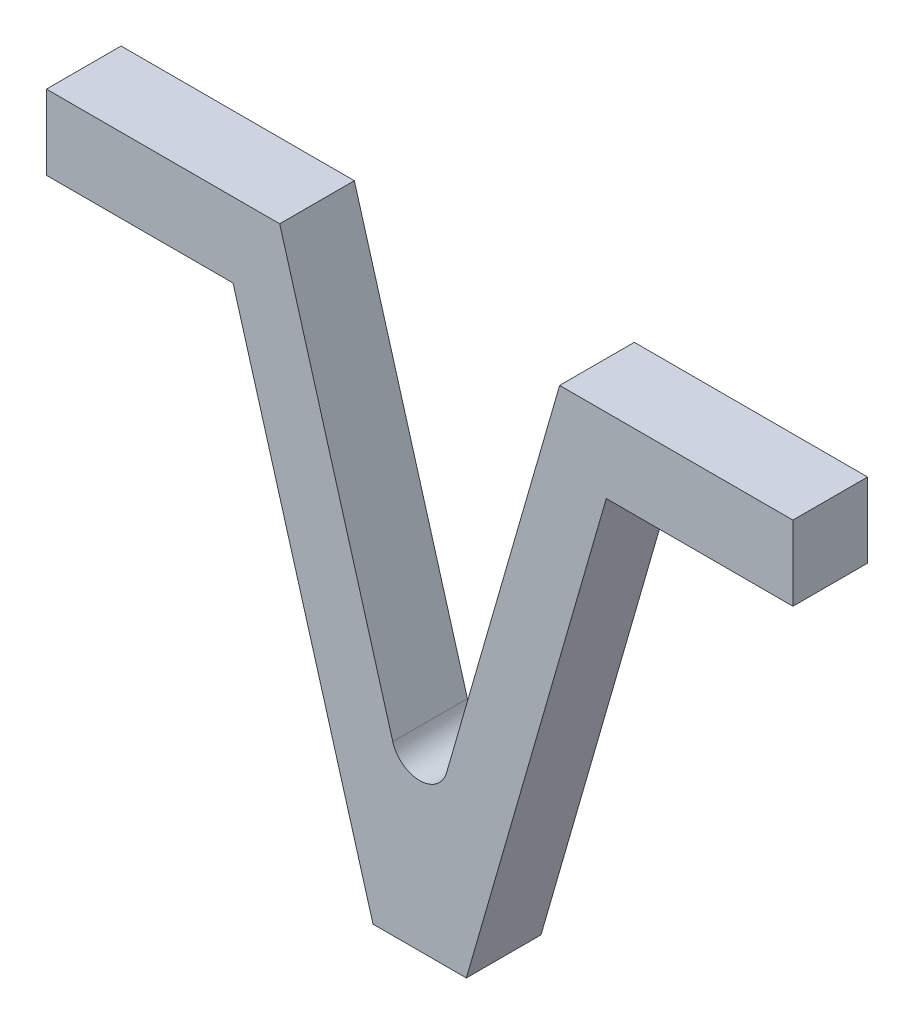
from build123d import *

# Parameters (mm, degrees)
BOSS_EXTRU_1_DEPTH = 8
CONG_1_R           = 3


with BuildPart() as part:
    # Esquisse1 → Boss.-Extru.1 (new body)
    with BuildSketch(Plane.XY):
        Polygon((-40.861442373, 48.763533187), (-15.861442373, 48.763533187), (-0.861442373, -3.236466813), (14.138557627, 48.763533187), (39.138557627, 48.763533187), (39.138557627, 40.763533187), (19.138557627, 40.763533187), (4.138557627, -11.236466813), (-5.861442373, -11.236466813), (-20.861442373, 40.763533187), (-40.861442373, 40.763533187), align=None)
    extrude(amount=BOSS_EXTRU_1_DEPTH)

    # Congé1
    cong_1_edges = [part.edges().sort_by_distance(p)[0] for p in [
        (-0.861442373, -3.236466813, 4),
    ]]
    fillet(cong_1_edges, radius=CONG_1_R)


solid = part.part
